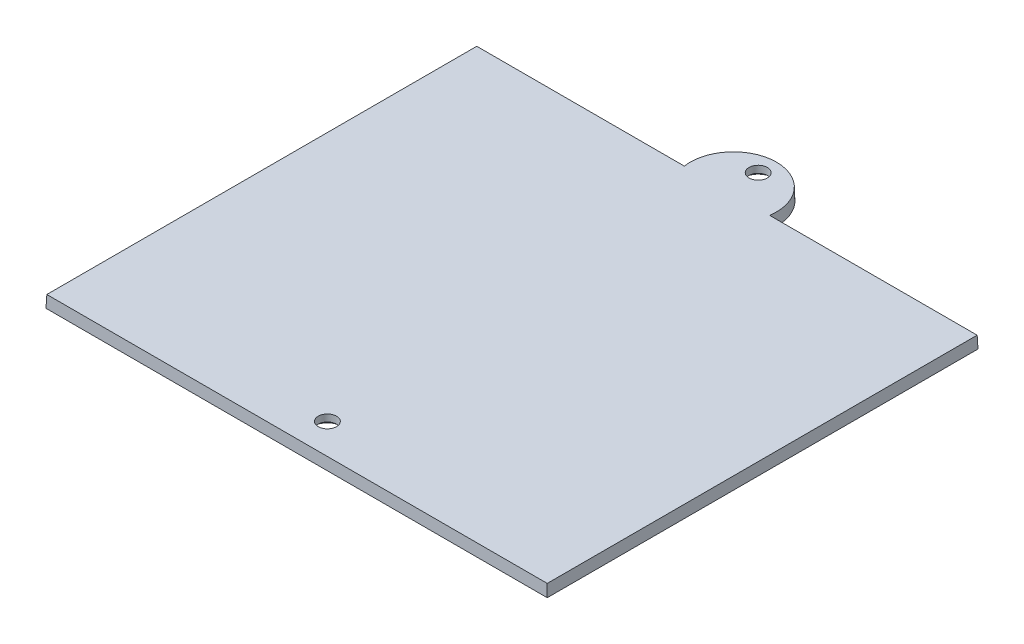
from build123d import *

# Parameters (mm, degrees)
BOSS_EXTRUDE1_DEPTH                       = 2
BOSS_EXTRUDE1_TAPER                       = 2
CSK_FOR_3_FLAT_HEAD_MACHINE_SCREW_2_COUNT = 2
CSK_FOR_3_FLAT_HEAD_MACHINE_SCREW_2_PITCH = 71.73786937


with BuildPart() as part:
    # Sketch1 → Boss-Extrude1 (new body)
    with BuildSketch(Plane(origin=(0, 56.683920775, 0), x_dir=(-1, 0, 0), z_dir=(0, -1, 0))):
        with BuildLine():
            ThreePointArc((-45.115607871, -113.170136337), (-52.296311179, -104.920136337), (-59.477014487, -113.170136337))
            Line((-59.477014487, -113.170136337), (-94.033723565, -113.170136337))
            Line((-94.033723565, -113.170136337), (-94.033723565, -184.908005707))
            Line((-94.033723565, -184.908005707), (-10.558898793, -184.908005707))
            Line((-10.558898793, -184.908005707), (-10.558898793, -113.170136337))
            Line((-10.558898793, -113.170136337), (-45.115607871, -113.170136337))
        make_face()
    extrude(amount=-BOSS_EXTRUDE1_DEPTH, taper=BOSS_EXTRUDE1_TAPER)

    # Sketch3 → CSK for #3 Flat Head Machine Screw (100)1 (revolve, cut)
    with BuildSketch(Plane(origin=(52.296311179, 56.683920775, 108.045136337), x_dir=(0, 0, -1), z_dir=(1, 0, 0))):
        Polygon((0, 0), (0, 2), (1.524, 2), (1.524, 0.84186866), (2.5273, 0), align=None)
    csk_for_3_flat_head_machine_screw_100 = revolve(axis=Axis((52.296311179, 50.333920775, 108.045136337), (0, 1, 0)), mode=Mode.SUBTRACT)

    # CSK for _3 Flat Head Machine Screw _ 2: CSK for #3 Flat Head Machine Screw (100)1 ×2
    with Locations(*[(0, 0, i * CSK_FOR_3_FLAT_HEAD_MACHINE_SCREW_2_PITCH) for i in range(1, CSK_FOR_3_FLAT_HEAD_MACHINE_SCREW_2_COUNT)]):
        add(csk_for_3_flat_head_machine_screw_100, mode=Mode.SUBTRACT)


solid = part.part
